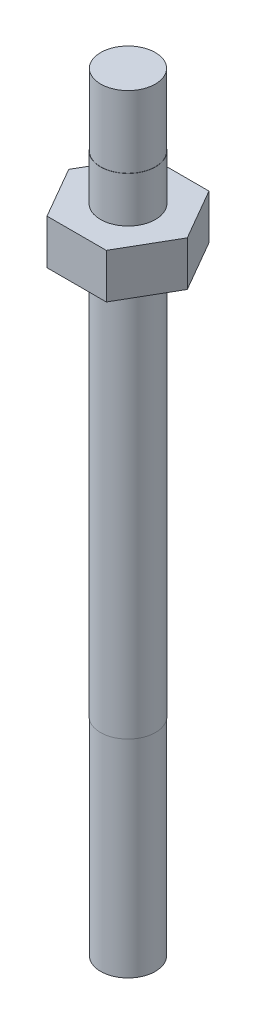
from build123d import *

# Parameters (mm, degrees)
BOSS_EXTRUDE1_DEPTH = 2.7432


with BuildPart() as part:
    # Sketch1 → Revolve1 (revolve)
    with BuildSketch(Plane.XY, mode=Mode.PRIVATE) as revolve1_sk:
        Polygon((0, 0), (1.6764, 0), (1.6764, 12.7), (1.6891, 12.7), (1.6891, 37.211), (3.1115, 37.211), (3.1115, 39.9542), (1.6891, 39.9542), (1.6891, 42.7482), (1.6764, 42.7482), (1.6764, 47.1424), (0, 47.1424), align=None)
    revolve(revolve1_sk.sketch.rotate(Axis((0, 0, 0), (0, 1, 0)), 90), axis=Axis((0, 0, 0), (0, 1, 0)))  # turned: the seam where the file's is

    # Sketch2 → Boss-Extrude1 (add)
    with BuildSketch(Plane(origin=(0, 39.9542, 0), x_dir=(1, 0, 0), z_dir=(0, 1, 0))):
        Polygon((3.636844816, 0), (1.818422408, 3.1496), (-1.818422408, 3.1496), (-3.636844816, 0), (-1.818422408, -3.1496), (1.818422408, -3.1496), align=None)
    extrude(amount=-BOSS_EXTRUDE1_DEPTH)


solid = part.part
